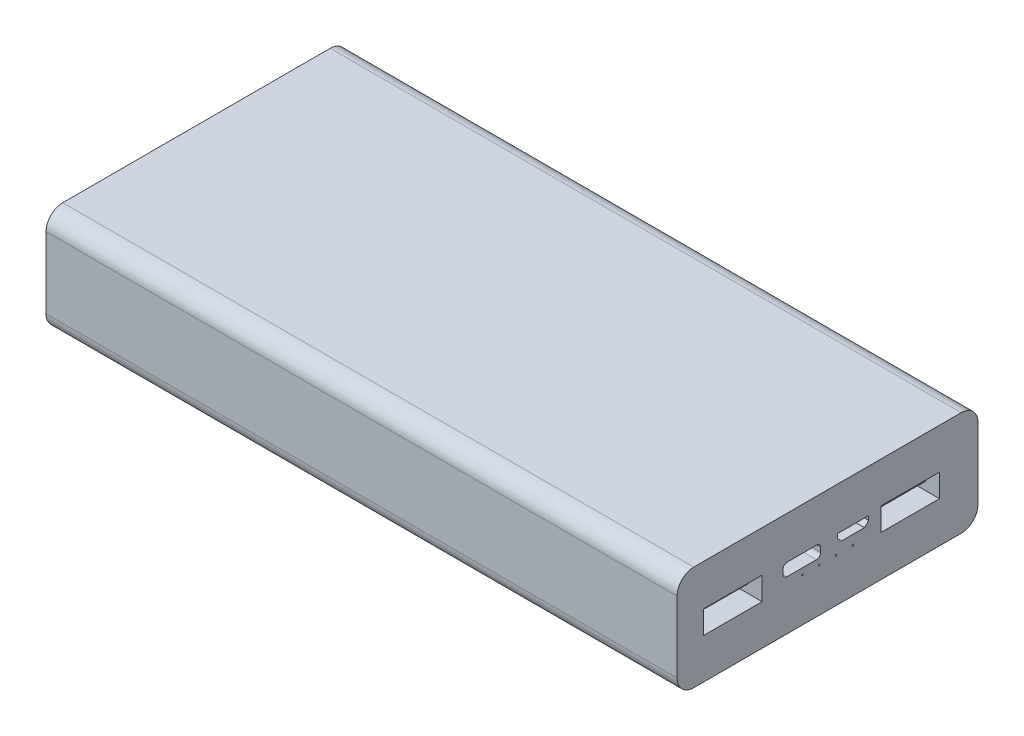
from build123d import *

# Parameters (mm, degrees)
SKETCH_1_W          = 151
SKETCH_1_H          = 72
EXTRUDE_1_DEPTH     = 25
FILLET_1_R          = 4
FILLET_2_R          = 4
FILLET_3_R          = 4
FILLET_4_R          = 4
SKETCH_2_R          = 0.2
SKETCH_2_W          = 14
SKETCH_2_H          = 5.5
CUT_EXTRUDE_1_DEPTH = 15
SKETCH_3_W          = 12.373268072
SKETCH_3_H          = 1.582389444
SKETCH_3_W_2        = 7.077543374
SKETCH_3_H_2        = 0.5
SKETCH_3_W_3        = 3.808702178
SKETCH_3_H_3        = 0.2
EXTRUDE_2_DEPTH     = 13
CHAMFER_1_SIZE      = 0.5
CHAMFER_2_SIZE      = 0.5
CHAMFER_3_SIZE      = 0.5
CHAMFER_4_SIZE      = 0.5
CHAMFER_5_SIZE      = 0.5
CUT_EXTRUDE_2_DEPTH = 3


with BuildPart() as part:
    # 草图1 → 凸台-拉伸1 (new body)
    with BuildSketch(Plane(origin=(0, 0, 0), x_dir=(1, 0, 0), z_dir=(0, 1, 0))):
        with Locations((-21.814590862, -0.38165894)):
            Rectangle(SKETCH_1_W, SKETCH_1_H)
    extrude(amount=EXTRUDE_1_DEPTH)

    # 圆角1
    fillet_1_edges = [part.edges().sort_by_distance(p)[0] for p in [
        (-21.814590862, 25, 36.38165894),
    ]]
    fillet(fillet_1_edges, radius=FILLET_1_R)

    # 圆角2
    fillet_2_edges = [part.edges().sort_by_distance(p)[0] for p in [
        (-21.814590862, 25, -35.61834106),
    ]]
    fillet(fillet_2_edges, radius=FILLET_2_R)

    # 圆角3
    fillet_3_edges = [part.edges().sort_by_distance(p)[0] for p in [
        (-21.814590862, 0, 36.38165894),
    ]]
    fillet(fillet_3_edges, radius=FILLET_3_R)

    # 圆角4
    fillet_4_edges = [part.edges().sort_by_distance(p)[0] for p in [
        (-21.814590862, 0, -35.61834106),
    ]]
    fillet(fillet_4_edges, radius=FILLET_4_R)

    # 草图2 → 切除-拉伸1 (cut)
    with BuildSketch(Plane(origin=(53.685409138, 0, 0), x_dir=(0, 0, -1), z_dir=(1, 0, 0))):
        with Locations((-6.38165894, 10.438981293)):
            Circle(SKETCH_2_R)
        with Locations((-2.38165894, 10.438981293)):
            Circle(SKETCH_2_R)
        with Locations((1.61834106, 10.438981293)):
            Circle(SKETCH_2_R)
        with Locations((5.61834106, 10.438981293)):
            Circle(SKETCH_2_R)
        with Locations((-23.032936311, 12.408130846)):
            Rectangle(SKETCH_2_W, SKETCH_2_H)
        with BuildLine():
            Line((-10.032936311, 14.854810604), (-3.032936311, 14.854810604))
            ThreePointArc((-3.032936311, 14.854810604), (-2.32582953, 14.561917385), (-2.032936311, 13.854810604))
            Line((-2.032936311, 13.854810604), (-2.032936311, 12.854810604))
            ThreePointArc((-2.032936311, 12.854810604), (-2.32582953, 12.147703823), (-3.032936311, 11.854810604))
            Line((-3.032936311, 11.854810604), (-10.032936311, 11.854810604))
            ThreePointArc((-10.032936311, 11.854810604), (-10.740043093, 12.147703823), (-11.032936311, 12.854810604))
            Line((-11.032936311, 12.854810604), (-11.032936311, 13.854810604))
            ThreePointArc((-11.032936311, 13.854810604), (-10.740043093, 14.561917385), (-10.032936311, 14.854810604))
        make_face()
        Polygon((1.967063689, 14.74117963), (9.467063689, 14.74117963), (9.467063689, 13.74117963), (8.467063689, 12.74117963), (2.967063689, 12.74117963), (1.967063689, 13.74117963), align=None)
        with Locations((19.400712994, 12.527228442)):
            Rectangle(SKETCH_2_W, SKETCH_2_H)
    extrude(amount=-CUT_EXTRUDE_1_DEPTH, mode=Mode.SUBTRACT)

    # 草图3 → 凸台-拉伸2 (add)
    with BuildSketch(Plane(origin=(38.685409138, 0, 0), x_dir=(0, 0, -1), z_dir=(1, 0, 0))):
        with Locations((-23.032936311, 13.344739888)):
            Rectangle(SKETCH_3_W, SKETCH_3_H)
        with Locations((19.400712994, 13.344739888)):
            Rectangle(SKETCH_3_W, SKETCH_3_H)
        with Locations((-6.532936311, 13.198610031)):
            Rectangle(SKETCH_3_W_2, SKETCH_3_H_2)
        with Locations((5.717063689, 13.913029352)):
            Rectangle(SKETCH_3_W_3, SKETCH_3_H_3)
    extrude(amount=EXTRUDE_2_DEPTH)

    # 倒角1
    chamfer_1_edges = [part.edges().sort_by_distance(p)[0] for p in [
        (51.685409138, 12.553545166, 23.032936311),
    ]]
    chamfer(chamfer_1_edges, length=CHAMFER_1_SIZE)

    # 倒角2
    chamfer_2_edges = [part.edges().sort_by_distance(p)[0] for p in [
        (51.685409138, 14.13593461, 23.032936311),
    ]]
    chamfer(chamfer_2_edges, length=CHAMFER_2_SIZE)

    # 倒角3
    chamfer_3_edges = [part.edges().sort_by_distance(p)[0] for p in [
        (51.685409138, 13.344739888, 29.219570347),
    ]]
    chamfer(chamfer_3_edges, length=CHAMFER_3_SIZE)

    # 倒角4
    chamfer_4_edges = [part.edges().sort_by_distance(p)[0] for p in [
        (51.685409138, 13.344739888, 16.846302275),
    ]]
    chamfer(chamfer_4_edges, length=CHAMFER_4_SIZE)

    # 倒角5
    chamfer_5_edges = [part.edges().sort_by_distance(p)[0] for p in [
        (51.685409138, 13.344739888, -13.214078958),
        (51.685409138, 12.553545166, -19.400712994),
        (51.685409138, 13.344739888, -25.58734703),
        (51.685409138, 14.13593461, -19.400712994),
    ]]
    chamfer(chamfer_5_edges, length=CHAMFER_5_SIZE)

    # 草图4 → 切除-拉伸2 (cut)
    with BuildSketch(Plane(origin=(0, 0, -35.61834106), x_dir=(-1, 0, 0), z_dir=(0, 0, -1))):
        with BuildLine():
            Line((-40.885409138, 14.323868956), (-30.485409138, 14.323868956))
            ThreePointArc((-30.485409138, 14.323868956), (-29.884368374, 14.07490972), (-29.635409138, 13.473868956))
            Line((-29.635409138, 13.473868956), (-29.635409138, 10.378810207))
            ThreePointArc((-29.635409138, 10.378810207), (-29.884368374, 9.777769443), (-30.485409138, 9.528810207))
            Line((-30.485409138, 9.528810207), (-40.885409138, 9.528810207))
            ThreePointArc((-40.885409138, 9.528810207), (-41.486449902, 9.777769443), (-41.735409138, 10.378810207))
            Line((-41.735409138, 10.378810207), (-41.735409138, 13.473868956))
            ThreePointArc((-41.735409138, 13.473868956), (-41.486449902, 14.07490972), (-40.885409138, 14.323868956))
        make_face()
        with BuildLine():
            Line((-40.885409138, 14.273868956), (-30.485409138, 14.273868956))
            ThreePointArc((-30.485409138, 14.273868956), (-29.919723713, 14.03955438), (-29.685409138, 13.473868956))
            Line((-29.685409138, 13.473868956), (-29.685409138, 10.378810207))
            ThreePointArc((-29.685409138, 10.378810207), (-29.919723713, 9.813124782), (-30.485409138, 9.578810207))
            Line((-30.485409138, 9.578810207), (-40.885409138, 9.578810207))
            ThreePointArc((-40.885409138, 9.578810207), (-41.451094563, 9.813124782), (-41.685409138, 10.378810207))
            Line((-41.685409138, 10.378810207), (-41.685409138, 13.473868956))
            ThreePointArc((-41.685409138, 13.473868956), (-41.451094563, 14.03955438), (-40.885409138, 14.273868956))
        make_face(mode=Mode.SUBTRACT)
    extrude(amount=-CUT_EXTRUDE_2_DEPTH, mode=Mode.SUBTRACT)

    # 切除-扫描1: sweep along a path in 草图5
    with BuildLine(Plane(origin=(0, 0, -35.61834106), x_dir=(-1, 0, 0), z_dir=(0, 0, -1))) as sweep_1_path:
        Line((-40.935409138, 14.823868956), (-30.435409138, 14.823868956))
        ThreePointArc((-30.435409138, 14.823868956), (-29.516170322, 14.443107771), (-29.135409138, 13.523868956))
        Line((-29.135409138, 13.523868956), (-29.135409138, 10.328810207))
        ThreePointArc((-29.135409138, 10.328810207), (-29.516170322, 9.409571391), (-30.435409138, 9.028810207))
        Line((-30.435409138, 9.028810207), (-40.935409138, 9.028810207))
        ThreePointArc((-40.935409138, 9.028810207), (-41.854647953, 9.409571391), (-42.235409138, 10.328810207))
        Line((-42.235409138, 10.328810207), (-42.235409138, 13.523868956))
        ThreePointArc((-42.235409138, 13.523868956), (-41.854647953, 14.443107771), (-40.935409138, 14.823868956))
    # 草图6 → 切除-扫描1 (sweep, cut)
    with BuildSketch(Plane(origin=(0, 11, 0), x_dir=(1, 0, 0), z_dir=(0, 1, 0))):
        with BuildLine():
            Line((41.735409138, 35.51679266), (41.735409138, 35.61834106))
            Line((41.735409138, 35.61834106), (42.235409138, 35.61834106))
            add(Edge.make_bspline(
                [(42.235409138, 35.61834106), (42.184892706, 35.515744093), (41.735409138, 35.51679266)],
                knots=[0, 0, 0, 1, 1, 1], degree=2))
        make_face()
    sweep(path=sweep_1_path.line, mode=Mode.SUBTRACT)


solid = part.part
